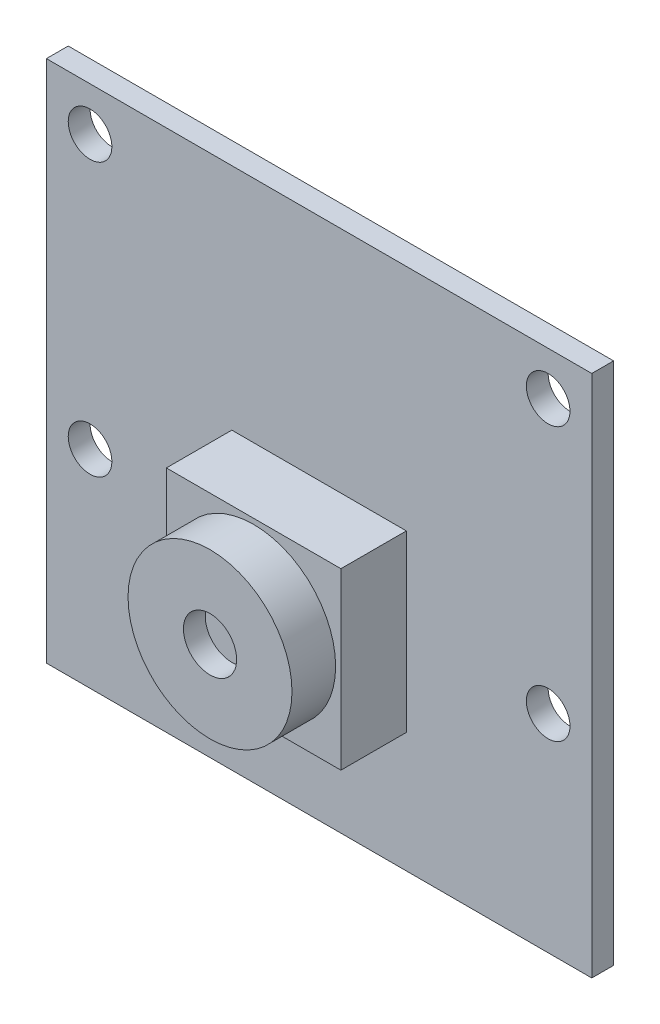
from build123d import *

# Parameters (mm, degrees)
SKETCH1_W               = 25
SKETCH1_H               = 24
BOSS_EXTRUDE1_DEPTH     = 1
SKETCH2_W               = 8
SKETCH2_H               = 8
BOSS_EXTRUDE2_DEPTH     = 3
SKETCH3_R               = 3.757777991
BOSS_EXTRUDE3_DEPTH     = 2
SKETCH4_R               = 1.219033686
CUT_EXTRUDE1_DEPTH      = 1
CUT_EXTRUDE2_DEPTH      = 19.034688797
CUT_EXTRUDE2_DEPTH_BACK = 19.034688797
SKETCH5_R               = 1


with BuildPart() as part:
    # Sketch1 → Boss-Extrude1 (new body)
    with BuildSketch(Plane.XY):
        Rectangle(SKETCH1_W, SKETCH1_H)
    extrude(amount=BOSS_EXTRUDE1_DEPTH)

    # Sketch5 → Cut-Extrude2 (cut, two sides: drawn at the far end of the back side and taken through both)
    with BuildSketch(Plane.XY.offset(1).offset(-CUT_EXTRUDE2_DEPTH_BACK)):
        with Locations((-10.5, -2.5)):
            Circle(SKETCH5_R)
        with Locations((-10.5, 10)):
            Circle(SKETCH5_R)
        with Locations((10.5, 10)):
            Circle(SKETCH5_R)
        with Locations((10.5, -2.5)):
            Circle(SKETCH5_R)
    extrude(amount=CUT_EXTRUDE2_DEPTH + CUT_EXTRUDE2_DEPTH_BACK, mode=Mode.SUBTRACT)


with BuildPart() as body_2:
    # Sketch2 → Boss-Extrude2 (new body)
    with BuildSketch(Plane.XY.offset(1)):
        with Locations((0, -2.5)):
            Rectangle(SKETCH2_W, SKETCH2_H)
    extrude(amount=BOSS_EXTRUDE2_DEPTH)


with BuildPart() as body_3:
    # Sketch3 → Boss-Extrude3 (new body)
    with BuildSketch(Plane.XY.offset(4)):
        with Locations((0, -2.5)):
            Circle(SKETCH3_R)
    extrude(amount=BOSS_EXTRUDE3_DEPTH)

    # Sketch4 → Cut-Extrude1 (cut)
    with BuildSketch(Plane.XY.offset(6)):
        with Locations((0, -2.5)):
            Circle(SKETCH4_R)
    extrude(amount=-CUT_EXTRUDE1_DEPTH, mode=Mode.SUBTRACT)


solid = Compound([part.part, body_2.part, body_3.part])
